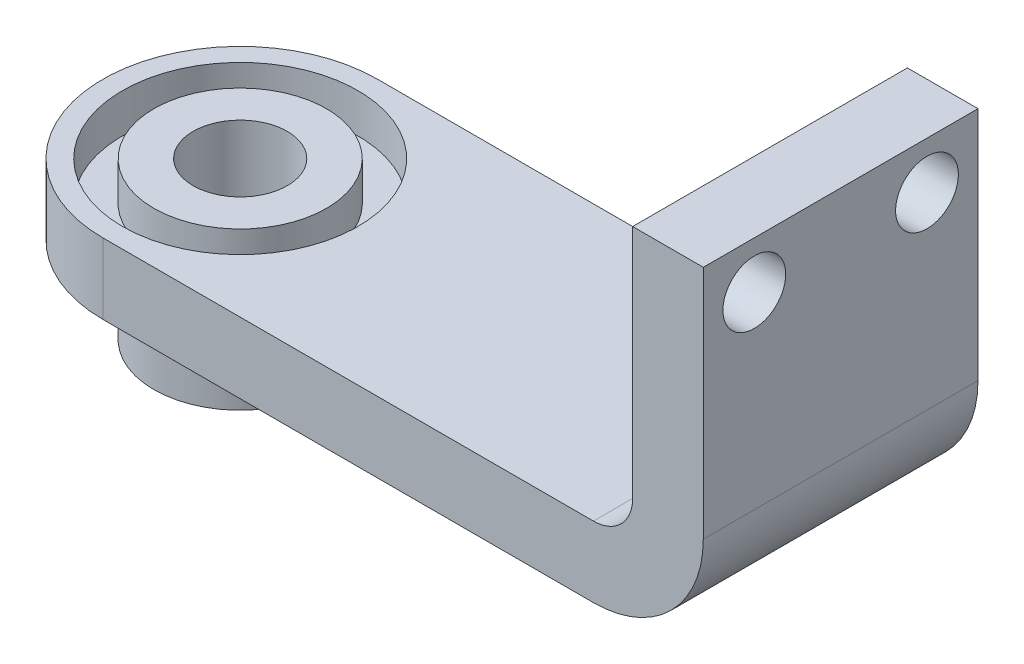
from build123d import *

# Parameters (mm, degrees)
BOSS_EXTRUDE1_DEPTH = 35
BOSS_EXTRUDE2_DEPTH = 9
SKETCH12_R          = 11
SKETCH12_R_2        = 6
BOSS_EXTRUDE3_DEPTH = 20
SKETCH7_R           = 4
CUT_EXTRUDE1_DEPTH  = 35
SKETCH9_R           = 15
CUT_EXTRUDE2_DEPTH  = 5
SKETCH10_R          = 11
CUT_EXTRUDE3_DEPTH  = 25


with BuildPart() as part:
    # Sketch5 → Boss-Extrude1 (new body)
    with BuildSketch(Plane.XY):
        with BuildLine():
            Line((-17.5, 0), (-17.5, -9))
            Line((-17.5, -9), (45, -9))
            ThreePointArc((45, -9), (54.899494937, -4.899494937), (59, 5))
            Line((59, 5), (59, 35))
            Line((59, 35), (50, 35))
            Line((50, 35), (50, 5))
            ThreePointArc((50, 5), (48.535533906, 1.464466094), (45, 0))
            Line((45, 0), (-17.5, 0))
        make_face()
    extrude(amount=-BOSS_EXTRUDE1_DEPTH)

    # Sketch8 → Boss-Extrude2 (add)
    with BuildSketch(Plane(origin=(0, 0, 0), x_dir=(1, 0, 0), z_dir=(0, 1, 0))):
        with BuildLine():
            Line((-17.5, 35), (-17.5, 0))
            ThreePointArc((-17.5, 0), (-35, 17.5), (-17.5, 35))
        make_face()
    extrude(amount=-BOSS_EXTRUDE2_DEPTH)

    # Sketch7 → Cut-Extrude1 (cut)
    with BuildSketch(Plane.ZY.offset(-50)):
        with Locations((-28.502110987, 29)):
            Circle(SKETCH7_R)
        with Locations((-6.5, 29)):
            Circle(SKETCH7_R)
    extrude(amount=-CUT_EXTRUDE1_DEPTH, mode=Mode.SUBTRACT)

    # Sketch9 → Cut-Extrude2 (cut)
    with BuildSketch(Plane(origin=(0, 0, 0), x_dir=(1, 0, 0), z_dir=(0, 1, 0))):
        with Locations((-17.5, 17.5)):
            Circle(SKETCH9_R)
    extrude(amount=-CUT_EXTRUDE2_DEPTH, mode=Mode.SUBTRACT)

    # Sketch10 → Cut-Extrude3 (cut)
    with BuildSketch(Plane(origin=(0, -5, 0), x_dir=(1, 0, 0), z_dir=(0, 1, 0))):
        with Locations((-17.5, 17.5)):
            Circle(SKETCH10_R)
    extrude(amount=-CUT_EXTRUDE3_DEPTH, mode=Mode.SUBTRACT)


with BuildPart() as body_2:
    # Sketch12 → Boss-Extrude3 (new body)
    with BuildSketch(Plane(origin=(0, 0, 0), x_dir=(1, 0, 0), z_dir=(0, 1, 0))):
        with Locations((-17.5, 17.5)):
            Circle(SKETCH12_R)
        with Locations((-17.5, 17.5)):
            Circle(SKETCH12_R_2, mode=Mode.SUBTRACT)
    extrude(amount=-BOSS_EXTRUDE3_DEPTH)


solid = Compound([part.part, body_2.part])
